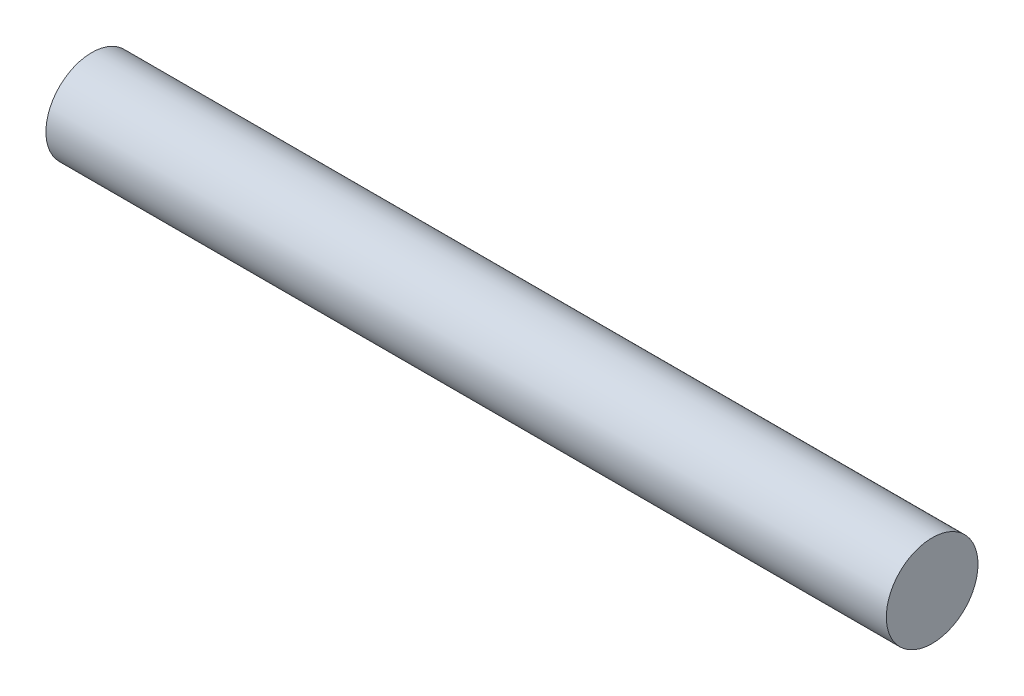
from build123d import *

# Parameters (mm, degrees)
SKETCH2_R           = 0.6
BOSS_EXTRUDE1_DEPTH = 11


with BuildPart() as part:
    # Sketch2 → Boss-Extrude1 (new body)
    with BuildSketch(Plane(origin=(0, 0, 0), x_dir=(0, 0, -1), z_dir=(1, 0, 0))):
        Circle(SKETCH2_R)
    extrude(amount=BOSS_EXTRUDE1_DEPTH)


solid = part.part
